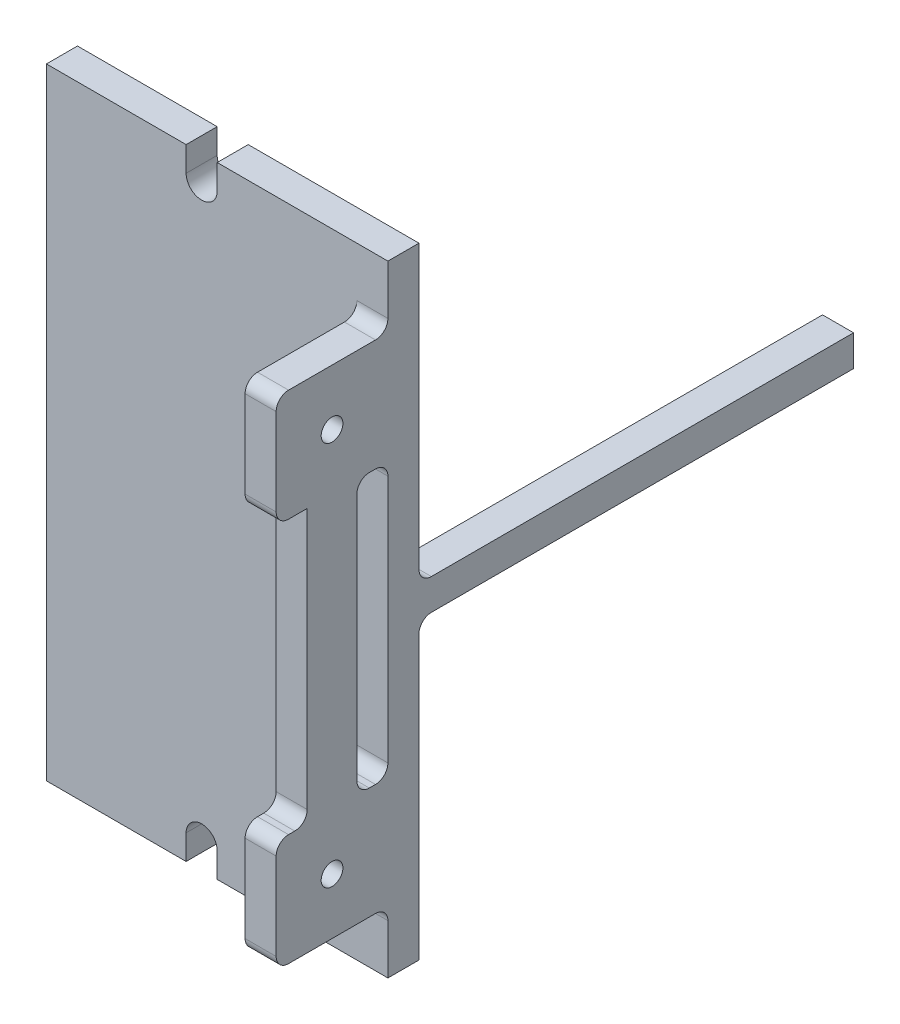
from build123d import *

# Parameters (mm, degrees)
BOSS_EXTRUDE3_DEPTH = 5
SKETCH4_W           = 5
SKETCH4_H           = 5
BOSS_EXTRUDE4_DEPTH = 70
SKETCH5_W           = 5
SKETCH5_H           = 18
BOSS_EXTRUDE5_DEPTH = 18
SKETCH6_R           = 1.75
CUT_EXTRUDE1_DEPTH  = 6
SKETCH7_W           = 8
SKETCH7_H           = 44
BOSS_EXTRUDE6_DEPTH = 5
FILLET1_R           = 2


with BuildPart() as part:
    # Sketch3 → Boss-Extrude3 (new body)
    with BuildSketch(Plane.XY):
        with BuildLine():
            Line((22.5, 100), (0, 100))
            Line((0, 100), (0, 0))
            Line((0, 0), (22.5, 0))
            Line((22.5, 0), (22.5, 4))
            ThreePointArc((22.5, 4), (25, 6.5), (27.5, 4))
            Line((27.5, 4), (27.5, 0))
            Line((27.5, 0), (55, 0))
            Line((55, 0), (55, 100))
            Line((55, 100), (27.5, 100))
            Line((27.5, 100), (27.5, 96))
            ThreePointArc((27.5, 96), (25, 93.5), (22.5, 96))
            Line((22.5, 96), (22.5, 100))
        make_face()
    extrude(amount=BOSS_EXTRUDE3_DEPTH)

    # Sketch4 → Boss-Extrude4 (add)
    with BuildSketch(Plane(origin=(0, 0, 0), x_dir=(-1, 0, 0), z_dir=(0, 0, -1))):
        with Locations((-52.5, 50)):
            Rectangle(SKETCH4_W, SKETCH4_H)
    extrude(amount=BOSS_EXTRUDE4_DEPTH)

    # Sketch5 → Boss-Extrude5 (add)
    with BuildSketch(Plane.XY.offset(5)):
        with Locations((52.5, 19)):
            Rectangle(SKETCH5_W, SKETCH5_H)
        with Locations((52.5, 81)):
            Rectangle(SKETCH5_W, SKETCH5_H)
    extrude(amount=BOSS_EXTRUDE5_DEPTH)

    # Sketch6 → Cut-Extrude1 (cut, through all)
    with BuildSketch(Plane.ZY.offset(-50)):
        with Locations((14, 19)):
            Circle(SKETCH6_R)
        with Locations((14, 81)):
            Circle(SKETCH6_R)
    extrude(amount=-CUT_EXTRUDE1_DEPTH, mode=Mode.SUBTRACT)

    # Sketch7 → Boss-Extrude6 (add)
    with BuildSketch(Plane.ZY.offset(-50)):
        with Locations((14, 50)):
            Rectangle(SKETCH7_W, SKETCH7_H)
    extrude(amount=-BOSS_EXTRUDE6_DEPTH)

    # Fillet1
    fillet1_edges = [part.edges().sort_by_distance(p)[0] for p in [
        (52.5, 47.5, 0),
        (52.5, 52.5, 0),
        (52.5, 10, 5),
        (52.5, 28, 5),
        (52.5, 10, 23),
        (52.5, 28, 23),
        (52.5, 72, 5),
        (52.5, 90, 5),
        (52.5, 72, 23),
        (52.5, 90, 23),
        (52.5, 72, 10),
        (52.5, 28, 10),
        (52.5, 28, 18),
    ]]
    fillet(fillet1_edges, radius=FILLET1_R)


solid = part.part
